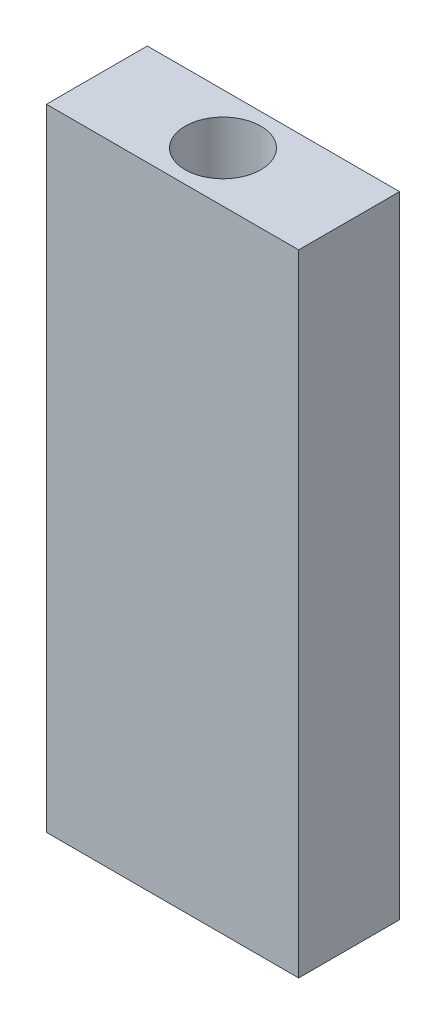
from build123d import *

# Parameters (mm, degrees)
SKETCH1_W           = 10
SKETCH1_H           = 4
SKETCH1_R           = 1.5
BOSS_EXTRUDE1_DEPTH = 25


with BuildPart() as part:
    # Sketch1 → Boss-Extrude1 (new body)
    with BuildSketch(Plane(origin=(0, 0, 0), x_dir=(1, 0, 0), z_dir=(0, 1, 0))):
        Rectangle(SKETCH1_W, SKETCH1_H)
        Circle(SKETCH1_R, mode=Mode.SUBTRACT)
    extrude(amount=BOSS_EXTRUDE1_DEPTH)


solid = part.part
